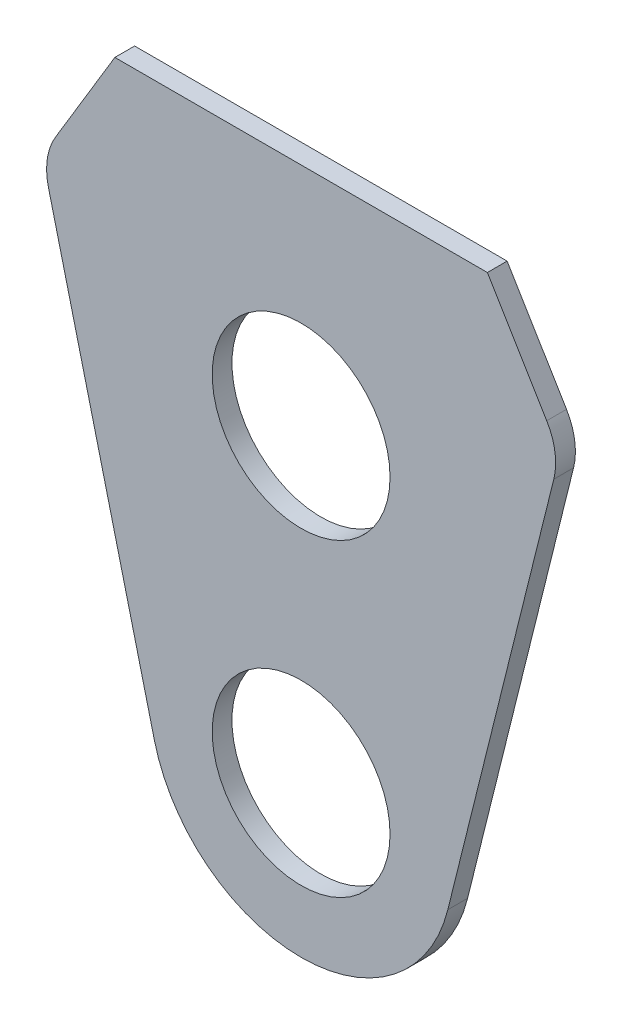
from build123d import *
from OCP.BRepFilletAPI import BRepFilletAPI_MakeChamfer

# Parameters (mm, degrees)
SKETCH1_R           = 14.2875
BOSS_EXTRUDE1_DEPTH = 3.175
CHAMFER1_SIZE       = 20
CHAMFER1_SIZE2      = 16.502650584
FILLET1_R           = 10


with BuildPart() as part:
    # Sketch1 → Boss-Extrude1 (new body)
    with BuildSketch(Plane.XY):
        with BuildLine():
            ThreePointArc((-23.568403012, -5.866262499), (0, -24.2875), (23.568403012, -5.866262499))
            Line((23.568403012, -5.866262499), (46.42676282, 85.9699))
            Line((46.42676282, 85.9699), (-46.42676282, 85.9699))
            Line((-46.42676282, 85.9699), (-23.568403012, -5.866262499))
        make_face()
        Circle(SKETCH1_R, mode=Mode.SUBTRACT)
        with Locations((0, 49.6824)):
            Circle(SKETCH1_R, mode=Mode.SUBTRACT)
    extrude(amount=BOSS_EXTRUDE1_DEPTH)

    # Chamfer1: one chamfer whose edges measure the first distance from different faces: ONE call of the kernel's chamfer builder (chamfer() names one face for all edges)
    chamfer1_edges_1 = [part.edges().sort_by_distance(p)[0] for p in [
        (-46.42676282, 85.9699, 1.5875),
    ]]
    chamfer1_side_1 = [part.faces().sort_by_distance(p)[0] for p in [
        (-34.997582916, 40.05181875, 1.5875),
    ]]
    chamfer1_edges_2 = [part.edges().sort_by_distance(p)[0] for p in [
        (46.42676282, 85.9699, 1.5875),
    ]]
    chamfer1_side_2 = [part.faces().sort_by_distance(p)[0] for p in [
        (34.997582916, 40.05181875, 1.5875),
    ]]
    chamfer1 = BRepFilletAPI_MakeChamfer(part.part.solid().wrapped)
    for e in chamfer1_edges_1:
        chamfer1.Add(CHAMFER1_SIZE, CHAMFER1_SIZE2, e.wrapped, chamfer1_side_1[0].wrapped)  # the first distance lies on this face
    for e in chamfer1_edges_2:
        chamfer1.Add(CHAMFER1_SIZE, CHAMFER1_SIZE2, e.wrapped, chamfer1_side_2[0].wrapped)  # the first distance lies on this face
    add(Compound.cast(chamfer1.Shape()), mode=Mode.REPLACE)

    # Fillet1
    fillet1_edges = [part.edges().sort_by_distance(p)[0] for p in [
        (-41.596078312, 66.562053979, 1.5875),
        (41.596078312, 66.562053979, 1.5875),
    ]]
    fillet(fillet1_edges, radius=FILLET1_R)


solid = part.part
